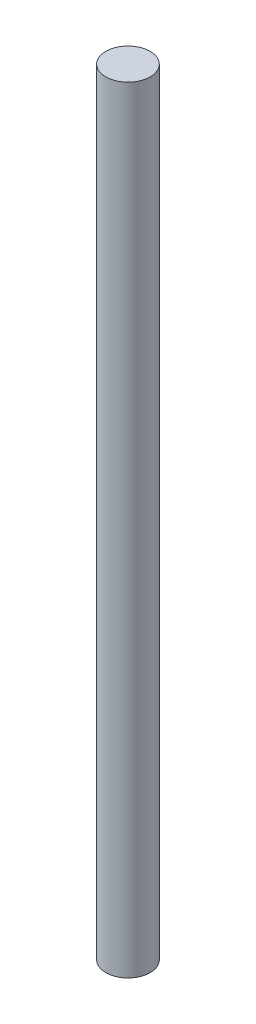
from build123d import *

# Parameters (mm, degrees)
SKETCH1_R           = 1
BOSS_EXTRUDE1_DEPTH = 17.5


with BuildPart() as part:
    # Sketch1 → Boss-Extrude1 (new body, symmetric)
    with BuildSketch(Plane(origin=(0, 0, 0), x_dir=(1, 0, 0), z_dir=(0, 1, 0))):
        Circle(SKETCH1_R)
    extrude(amount=BOSS_EXTRUDE1_DEPTH, both=True)


solid = part.part
